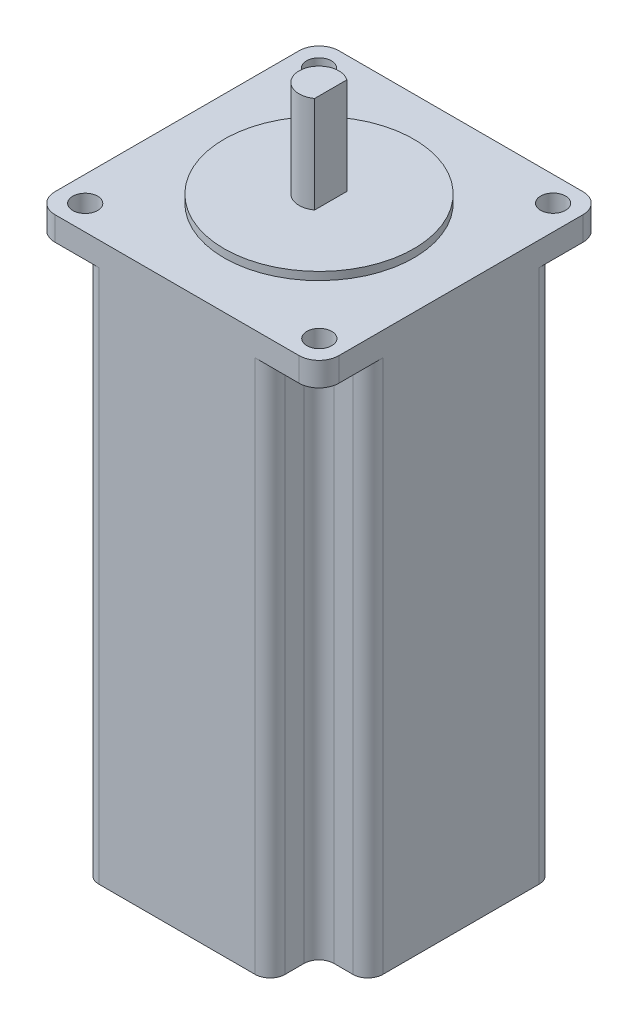
from build123d import *

# Parameters (mm, degrees)
BOSS_EXTRUDE1_DEPTH  = 112
SKETCH2_R            = 19.05
BOSS_EXTRUDE2_DEPTH  = 1.6
SKETCH3_R            = 4
BOSS_EXTRUDE3_DEPTH  = 19.4
SKETCH4_W            = 7.896046337
SKETCH4_H            = 7.324948646
CUT_EXTRUDE1_DEPTH   = 19.4
CUT_EXTRUDE2_DEPTH   = 107.2
MIRROR2_COPY_1_DEPTH = 107.2
FILLET1_R            = 3
SKETCH6_R            = 2.5
CUT_EXTRUDE3_DEPTH   = 107.2


with BuildPart() as part:
    # Sketch1 → Boss-Extrude1 (new body)
    with BuildSketch(Plane(origin=(0, 0, 0), x_dir=(1, 0, 0), z_dir=(0, 1, 0))):
        with BuildLine():
            Line((-24.5, -28.5), (24.5, -28.5))
            ThreePointArc((24.5, -28.5), (27.328427125, -27.328427125), (28.5, -24.5))
            Line((28.5, -24.5), (28.5, 24.5))
            ThreePointArc((28.5, 24.5), (27.328427125, 27.328427125), (24.5, 28.5))
            Line((24.5, 28.5), (-24.5, 28.5))
            ThreePointArc((-24.5, 28.5), (-27.328427125, 27.328427125), (-28.5, 24.5))
            Line((-28.5, 24.5), (-28.5, -24.5))
            ThreePointArc((-28.5, -24.5), (-27.328427125, -27.328427125), (-24.5, -28.5))
        make_face()
    extrude(amount=BOSS_EXTRUDE1_DEPTH)

    # Sketch2 → Boss-Extrude2 (add)
    with BuildSketch(Plane(origin=(0, 112, 0), x_dir=(1, 0, 0), z_dir=(0, 1, 0))):
        Circle(SKETCH2_R)
    extrude(amount=BOSS_EXTRUDE2_DEPTH)

    # Sketch3 → Boss-Extrude3 (add)
    with BuildSketch(Plane(origin=(0, 113.6, 0), x_dir=(1, 0, 0), z_dir=(0, 1, 0))):
        Circle(SKETCH3_R)
    extrude(amount=BOSS_EXTRUDE3_DEPTH)

    # Sketch4 → Cut-Extrude1 (cut)
    with BuildSketch(Plane(origin=(0, 133, 0), x_dir=(1, 0, 0), z_dir=(0, 1, 0))):
        with Locations((6.304367274, 0.076945889)):
            Rectangle(SKETCH4_W, SKETCH4_H)
    extrude(amount=-CUT_EXTRUDE1_DEPTH, mode=Mode.SUBTRACT)

    # Sketch5 → Cut-Extrude2 (cut)
    with BuildSketch(Plane.XZ):
        with BuildLine():
            Line((-28.5, 24.5), (-28.5, 18.683107864))
            Line((-28.5, 18.683107864), (-18.683107864, 18.683107864))
            Line((-18.683107864, 18.683107864), (-18.683107864, 28.5))
            Line((-18.683107864, 28.5), (-24.5, 28.5))
            ThreePointArc((-24.5, 28.5), (-27.328427125, 27.328427125), (-28.5, 24.5))
        make_face()
    cut_extrude2 = extrude(amount=-CUT_EXTRUDE2_DEPTH, mode=Mode.SUBTRACT)

    # Mirror1: Cut-Extrude2 across plane
    add(cut_extrude2.mirror(Plane(origin=(0, 0, 0), x_dir=(0, 0, 1), z_dir=(1, 0, 0))), mode=Mode.SUBTRACT)

    # Mirror2: Cut-Extrude2 across plane
    add(cut_extrude2.mirror(Plane.XY), mode=Mode.SUBTRACT)

    # Mirror2 copy 1 sketch → Mirror2 copy 1 (cut)
    with BuildSketch(Plane(origin=(0, 0, 0), x_dir=(-1, 0, 0), z_dir=(0, -1, 0))):
        with BuildLine():
            Line((-28.5, 24.5), (-28.5, 18.683107864))
            Line((-28.5, 18.683107864), (-18.683107864, 18.683107864))
            Line((-18.683107864, 18.683107864), (-18.683107864, 28.5))
            Line((-18.683107864, 28.5), (-24.5, 28.5))
            ThreePointArc((-24.5, 28.5), (-27.328427125, 27.328427125), (-28.5, 24.5))
        make_face()
    extrude(amount=-MIRROR2_COPY_1_DEPTH, mode=Mode.SUBTRACT)

    # Fillet1
    fillet1_edges = [part.edges().sort_by_distance(p)[0] for p in [
        (-18.683107864, 53.6, -18.683107864),
        (-18.683107864, 53.6, -28.5),
        (-28.5, 53.6, -18.683107864),
        (-18.683107864, 53.6, 28.5),
        (-18.683107864, 53.6, 18.683107864),
        (-28.5, 53.6, 18.683107864),
        (18.683107864, 53.6, 18.683107864),
        (18.683107864, 53.6, 28.5),
        (28.5, 53.6, 18.683107864),
        (18.683107864, 53.6, -28.5),
        (18.683107864, 53.6, -18.683107864),
        (28.5, 53.6, -18.683107864),
    ]]
    fillet(fillet1_edges, radius=FILLET1_R)

    # Sketch6 → Cut-Extrude3 (cut)
    with BuildSketch(Plane(origin=(0, 112, 0), x_dir=(1, 0, 0), z_dir=(0, 1, 0))):
        with Locations((23.5, 23.5)):
            Circle(SKETCH6_R)
        with Locations((23.564387561, -23.499955896)):
            Circle(SKETCH6_R)
        with Locations((-23.5, 23.5)):
            Circle(SKETCH6_R)
        with Locations((-23.435612439, -23.5)):
            Circle(SKETCH6_R)
    extrude(amount=-CUT_EXTRUDE3_DEPTH, mode=Mode.SUBTRACT)


solid = part.part
